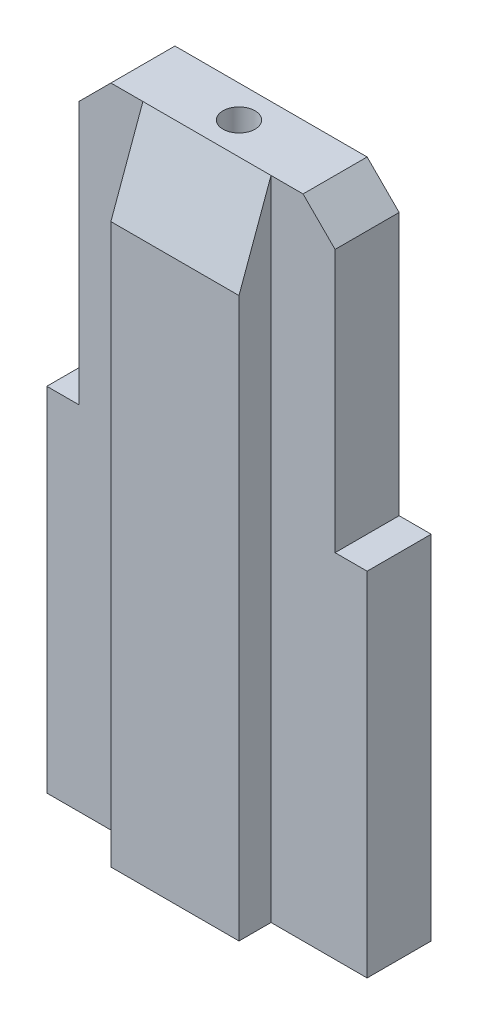
from build123d import *

# Parameters (mm, degrees)
AUFSATZ_LINEAR_AUSTRAGEN1_DEPTH = 0.5
SKIZZE2_W                       = 2
SKIZZE2_H                       = 10.1
AUFSATZ_LINEAR_AUSTRAGEN2_DEPTH = 0.5
FASE1_SIZE                      = 0.5
FASE1_SIZE2                     = 1.37373871
SKIZZE3_W                       = 2
SKIZZE3_H                       = 10.1
AUFSATZ_LINEAR_AUSTRAGEN3_DEPTH = 0.5
FASE3_SIZE                      = 0.5
FASE3_SIZE2                     = 1.37373871
FASE4_SIZE                      = 0.5
FASE5_SIZE                      = 0.5
SKIZZE4_R                       = 0.25
SCHNITT_LINEAR_AUSTRAGEN1_DEPTH = 11.452750834


with BuildPart() as part:
    # Skizze1 → Aufsatz-Linear austragen1 (new, symmetric)
    with BuildSketch(Plane.XY):
        Polygon((-2, 2.75), (-2, 7.35), (2, 7.35), (2, 2.75), (2.5, 2.75), (2.5, -2.75), (-2.5, -2.75), (-2.5, 2.75), align=None)
    extrude(amount=AUFSATZ_LINEAR_AUSTRAGEN1_DEPTH, both=True)

    # Skizze2 → Aufsatz-Linear austragen2 (add)
    with BuildSketch(Plane.XY.offset(0.5)):
        with Locations((0, 2.3)):
            Rectangle(SKIZZE2_W, SKIZZE2_H)
    extrude(amount=AUFSATZ_LINEAR_AUSTRAGEN2_DEPTH)

    # Fase1
    fase1_edges = [part.edges().sort_by_distance(p)[0] for p in [
        (0, 7.35, 1),
    ]]
    fase1_side = [part.faces().sort_by_distance(p)[0] for p in [
        (0, 7.35, 0.15),
    ]]
    chamfer(fase1_edges, length=FASE1_SIZE, length2=FASE1_SIZE2, reference=fase1_side[0])

    # Skizze3 → Aufsatz-Linear austragen3 (add)
    with BuildSketch(Plane(origin=(0, 0, -0.5), x_dir=(-1, 0, 0), z_dir=(0, 0, -1))):
        with Locations((0, 2.3)):
            Rectangle(SKIZZE3_W, SKIZZE3_H)
    extrude(amount=AUFSATZ_LINEAR_AUSTRAGEN3_DEPTH)

    # Fase3
    fase3_edges = [part.edges().sort_by_distance(p)[0] for p in [
        (0, 7.35, -1),
    ]]
    fase3_side = [part.faces().sort_by_distance(p)[0] for p in [
        (0, 7.35, -0.15),
    ]]
    chamfer(fase3_edges, length=FASE3_SIZE, length2=FASE3_SIZE2, reference=fase3_side[0])

    # Fase4
    fase4_edges = [part.edges().sort_by_distance(p)[0] for p in [
        (-2, 7.35, 0),
    ]]
    chamfer(fase4_edges, length=FASE4_SIZE)

    # Fase5
    fase5_edges = [part.edges().sort_by_distance(p)[0] for p in [
        (2, 7.35, 0),
    ]]
    chamfer(fase5_edges, length=FASE5_SIZE)

    # Skizze4 → Schnitt-Linear austragen1 (cut, through all)
    with BuildSketch(Plane(origin=(0, 7.35, 0), x_dir=(1, 0, 0), z_dir=(0, 1, 0))):
        Circle(SKIZZE4_R)
    extrude(amount=-SCHNITT_LINEAR_AUSTRAGEN1_DEPTH, mode=Mode.SUBTRACT)


solid = part.part
